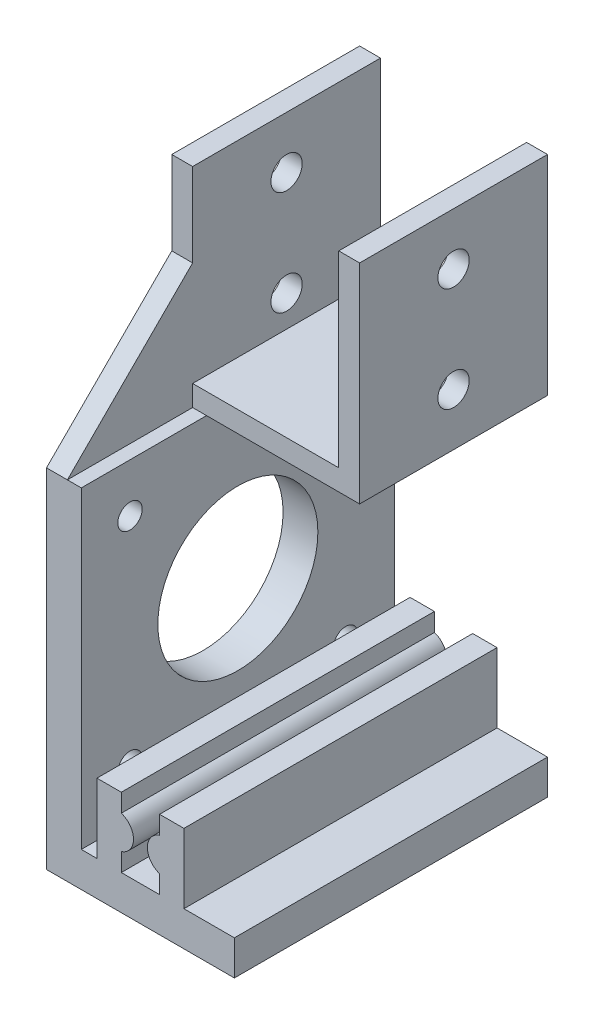
from build123d import *

# Parameters (mm, degrees)
SKETCH1_W            = 27
SKETCH1_H            = 27
BOSS_EXTRUDE1_DEPTH  = 30
SKETCH2_W            = 21
SKETCH2_H            = 27
CUT_EXTRUDE1_DEPTH   = 30
SKETCH3_R            = 2.25
CUT_EXTRUDE2_DEPTH   = 30
SKETCH5_W            = 5
SKETCH5_H            = 45
BOSS_EXTRUDE2_DEPTH  = 45
SKETCH6_R            = 1.75
SKETCH6_R_2          = 11.5
CUT_EXTRUDE3_DEPTH   = 10
SKETCH8_W            = 45
SKETCH8_H            = 5
BOSS_EXTRUDE4_DEPTH  = 5
SKETCH9_W            = 45
SKETCH9_H            = 5
BOSS_EXTRUDE5_DEPTH  = 22
BOSS_EXTRUDE6_DEPTH  = 45
BOSS_EXTRUDE10_START = -3
BOSS_EXTRUDE10_DEPTH = 3


with BuildPart() as part:
    # Sketch1 → Boss-Extrude1 (new body)
    with BuildSketch(Plane(origin=(0, 0, 0), x_dir=(1, 0, 0), z_dir=(0, 1, 0))):
        Rectangle(SKETCH1_W, SKETCH1_H)
    extrude(amount=BOSS_EXTRUDE1_DEPTH)

    # Sketch2 → Cut-Extrude1 (cut)
    with BuildSketch(Plane(origin=(0, 0, -13.5), x_dir=(-1, 0, 0), z_dir=(0, 0, -1))):
        with Locations((0, 16.5)):
            Rectangle(SKETCH2_W, SKETCH2_H)
    extrude(amount=-CUT_EXTRUDE1_DEPTH, mode=Mode.SUBTRACT)

    # Sketch3 → Cut-Extrude2 (cut)
    with BuildSketch(Plane.ZY.offset(13.5)):
        with Locations((0, 7.5)):
            Circle(SKETCH3_R)
        with Locations((0, 22.5)):
            Circle(SKETCH3_R)
    extrude(amount=-CUT_EXTRUDE2_DEPTH, mode=Mode.SUBTRACT)

    # Sketch5 → Boss-Extrude2 (add)
    with BuildSketch(Plane.XZ):
        with Locations((-11, 9)):
            Rectangle(SKETCH5_W, SKETCH5_H)
    extrude(amount=BOSS_EXTRUDE2_DEPTH)

    # Sketch6 → Cut-Extrude3 (cut)
    with BuildSketch(Plane(origin=(-8.5, 0, 0), x_dir=(0, 0, -1), z_dir=(1, 0, 0))):
        with Locations((-24.5, -38)):
            Circle(SKETCH6_R)
        with Locations((-24.5, -7)):
            Circle(SKETCH6_R)
        with Locations((6.5, -7)):
            Circle(SKETCH6_R)
        with Locations((6.5, -38)):
            Circle(SKETCH6_R)
        with Locations((-9, -22.5)):
            Circle(SKETCH6_R_2)
    extrude(amount=-CUT_EXTRUDE3_DEPTH, mode=Mode.SUBTRACT)

    # Sketch8 → Boss-Extrude4 (add)
    with BuildSketch(Plane(origin=(-8.5, 0, 0), x_dir=(0, 0, -1), z_dir=(1, 0, 0))):
        with Locations((-9, -47.5)):
            Rectangle(SKETCH8_W, SKETCH8_H)
    extrude(amount=-BOSS_EXTRUDE4_DEPTH)

    # Sketch9 → Boss-Extrude5 (add)
    with BuildSketch(Plane(origin=(-8.5, 0, 0), x_dir=(0, 0, -1), z_dir=(1, 0, 0))):
        with Locations((-9, -47.5)):
            Rectangle(SKETCH9_W, SKETCH9_H)
    extrude(amount=BOSS_EXTRUDE5_DEPTH)

    # Sketch10 → Boss-Extrude6 (add)
    with BuildSketch(Plane.XY.offset(31.5)):
        with BuildLine():
            Line((-6.25, -35), (-6.25, -45))
            Line((-6.25, -45), (-2.75, -45))
            Line((-2.75, -45), (-2.75, -42.384848004))
            ThreePointArc((-2.75, -42.384848004), (-6, -40), (-2.75, -37.615151996))
            Line((-2.75, -37.615151996), (-2.75, -35))
            Line((-2.75, -35), (-6.25, -35))
        make_face()
        with BuildLine():
            ThreePointArc((-2.75, -37.615151996), (-6, -40), (-2.75, -42.384848004))
            Line((-2.75, -42.384848004), (-2.75, -37.615151996))
        make_face()
        with BuildLine():
            Line((-2.75, -37.615151996), (-2.75, -42.384848004))
            ThreePointArc((-2.75, -42.384848004), (-1.484435563, -41.479019946), (-1, -40))
            ThreePointArc((-1, -40), (-1.484435563, -38.520980054), (-2.75, -37.615151996))
        make_face()
        with BuildLine():
            ThreePointArc((2.75, -37.615151996), (1, -40), (2.75, -42.384848004))
            Line((2.75, -42.384848004), (2.75, -37.615151996))
        make_face()
        with BuildLine():
            Line((2.75, -37.615151996), (2.75, -42.384848004))
            ThreePointArc((2.75, -42.384848004), (4.979019946, -42.015564437), (6, -40))
            ThreePointArc((6, -40), (4.979019946, -37.984435563), (2.75, -37.615151996))
        make_face()
        with BuildLine():
            Line((2.75, -42.384848004), (2.75, -45))
            Line((2.75, -45), (6.25, -45))
            Line((6.25, -45), (6.25, -35))
            Line((6.25, -35), (2.75, -35))
            Line((2.75, -35), (2.75, -37.615151996))
            ThreePointArc((2.75, -37.615151996), (4.979019946, -37.984435563), (6, -40))
            ThreePointArc((6, -40), (4.979019946, -42.015564437), (2.75, -42.384848004))
        make_face()
    extrude(amount=-BOSS_EXTRUDE6_DEPTH)

    # Sketch15 → Boss-Extrude10 (add)
    with BuildSketch(Plane.ZY.offset(13.5).offset(BOSS_EXTRUDE10_START)):
        Polygon((31.5, 0), (13.5, 18), (13.5, 0), align=None)
    extrude(amount=BOSS_EXTRUDE10_DEPTH)


solid = part.part
